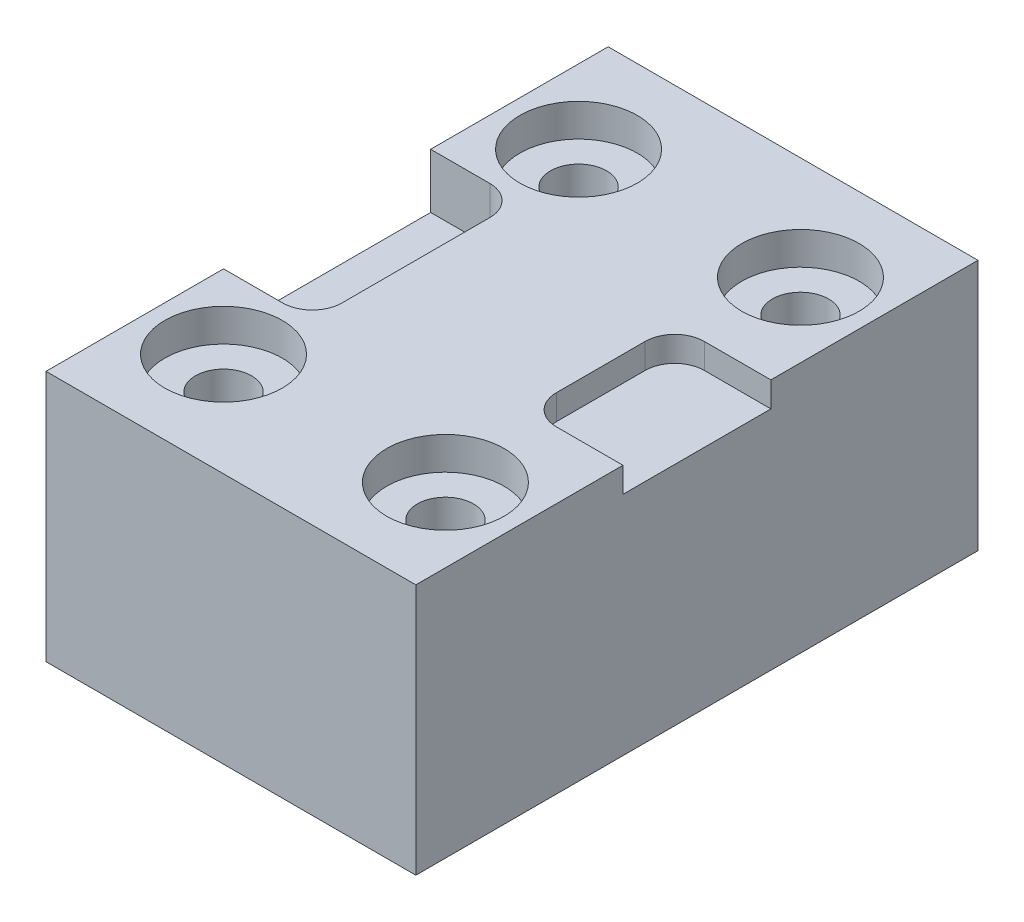
from build123d import *

# Parameters (mm, degrees)
SKETCH1_W                                           = 25
SKETCH1_H                                           = 38
BOSS_EXTRUDE1_DEPTH                                 = 17
CUT_EXTRUDE3_DEPTH                                  = 3.7
CUT_EXTRUDE4_DEPTH                                  = 1.7
CBORE_FOR_6_BINDING_HEAD_MACHINE_SCREW1_D           = 3.7973
CBORE_FOR_6_BINDING_HEAD_MACHINE_SCREW1_CBORE_D     = 7.9375
CBORE_FOR_6_BINDING_HEAD_MACHINE_SCREW1_CBORE_DEPTH = 2.2098


with BuildPart() as part:
    # Sketch1 → Boss-Extrude1 (new body)
    with BuildSketch(Plane(origin=(0, 0, 0), x_dir=(1, 0, 0), z_dir=(0, 1, 0))):
        with Locations((-18481.446731235, 11298.191283293)):
            Rectangle(SKETCH1_W, SKETCH1_H)
    extrude(amount=BOSS_EXTRUDE1_DEPTH)

    # Sketch2 → Cut-Extrude3 (cut)
    with BuildSketch(Plane(origin=(0, 17, 0), x_dir=(1, 0, 0), z_dir=(0, 1, 0))):
        with BuildLine():
            Line((-18493.946731235, 11291.191283293), (-18489.946731235, 11291.191283293))
            ThreePointArc((-18489.946731235, 11291.191283293), (-18488.532517672, 11291.777069731), (-18487.946731235, 11293.191283293))
            Line((-18487.946731235, 11293.191283293), (-18487.946731235, 11303.191283293))
            ThreePointArc((-18487.946731235, 11303.191283293), (-18488.532517672, 11304.605496855), (-18489.946731235, 11305.191283293))
            Line((-18489.946731235, 11305.191283293), (-18493.946731235, 11305.191283293))
            Line((-18493.946731235, 11305.191283293), (-18493.946731235, 11291.191283293))
        make_face()
    extrude(amount=-CUT_EXTRUDE3_DEPTH, mode=Mode.SUBTRACT)

    # Sketch2_6 → Cut-Extrude4 (cut)
    with BuildSketch(Plane(origin=(0, 17, 0), x_dir=(1, 0, 0), z_dir=(0, 1, 0))):
        with BuildLine():
            Line((-18475.446731235, 11301.191283293), (-18475.446731235, 11295.191283293))
            ThreePointArc((-18475.446731235, 11295.191283293), (-18474.860944797, 11293.777069731), (-18473.446731235, 11293.191283293))
            Line((-18473.446731235, 11293.191283293), (-18468.946731235, 11293.191283293))
            Line((-18468.946731235, 11293.191283293), (-18468.946731235, 11303.191283293))
            Line((-18468.946731235, 11303.191283293), (-18473.446731235, 11303.191283293))
            ThreePointArc((-18473.446731235, 11303.191283293), (-18474.860944797, 11302.605496855), (-18475.446731235, 11301.191283293))
        make_face()
    extrude(amount=-CUT_EXTRUDE4_DEPTH, mode=Mode.SUBTRACT)

    # CBORE for _6 Binding Head Machine Screw1 (through all)
    with Locations(Plane(origin=(0, 17, 0), x_dir=(1, 0, 0), z_dir=(0, 1, 0))):
        with Locations((-18488.946731235, 11310.191283293), (-18473.946731235, 11310.191283293), (-18473.946731235, 11286.191283293), (-18488.946731235, 11286.191283293)):
            CounterBoreHole(CBORE_FOR_6_BINDING_HEAD_MACHINE_SCREW1_D / 2, CBORE_FOR_6_BINDING_HEAD_MACHINE_SCREW1_CBORE_D / 2, CBORE_FOR_6_BINDING_HEAD_MACHINE_SCREW1_CBORE_DEPTH)


solid = part.part
